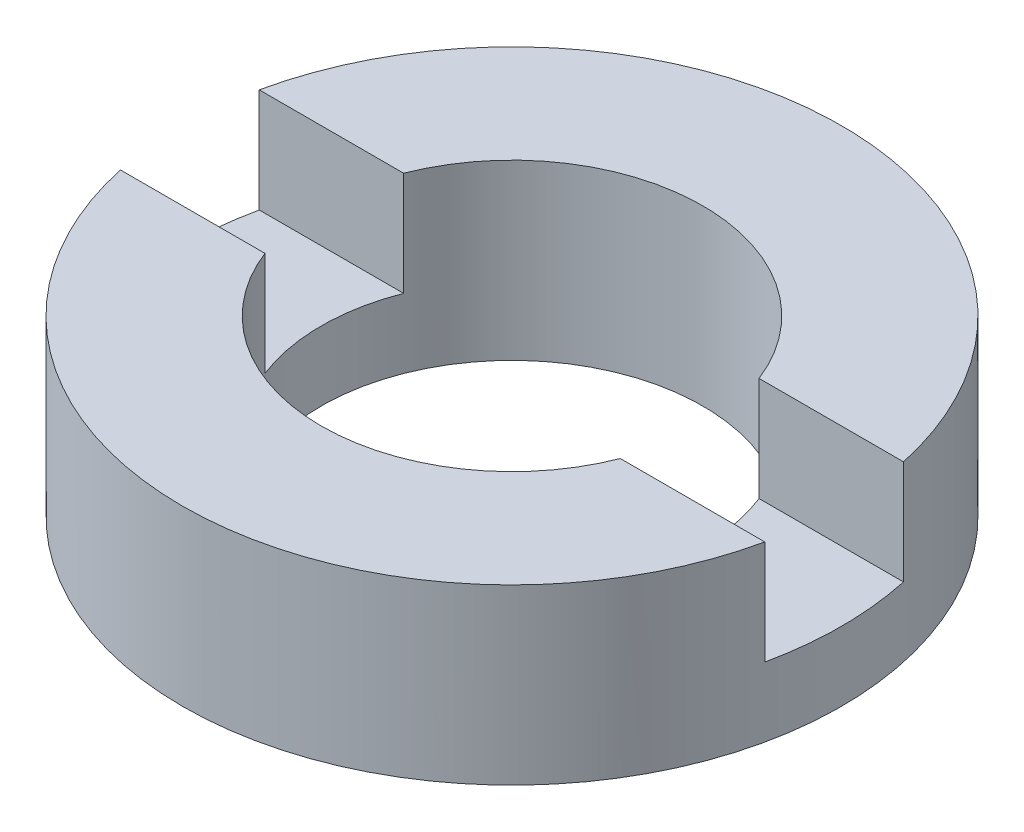
from build123d import *

# Parameters (mm, degrees)
SKETCH_1_W          = 2
SKETCH_1_H          = 2.5
SKETCH_2_W          = 53.705080546
SKETCH_2_H          = 2
CUT_EXTRUDE_1_DEPTH = 1.5


with BuildPart() as part:
    # 草图1 → 旋转1 (revolve)
    with BuildSketch(Plane.XY, mode=Mode.PRIVATE) as revolve_1_sk:
        with Locations((3.75, -3.214249787)):
            Rectangle(SKETCH_1_W, SKETCH_1_H)
    revolve(revolve_1_sk.sketch.rotate(Axis((0, 56.260842627, 0), (0, -1, 0)), 90), axis=Axis((0, 56.260842627, 0), (0, -1, 0)))  # turned: the seam where the file's is

    # 草图2 → 切除-拉伸1 (cut)
    with BuildSketch(Plane(origin=(0, -1.964249787, 0), x_dir=(1, 0, 0), z_dir=(0, 1, 0))):
        Rectangle(SKETCH_2_W, SKETCH_2_H)
    extrude(amount=-CUT_EXTRUDE_1_DEPTH, mode=Mode.SUBTRACT)


solid = part.part
